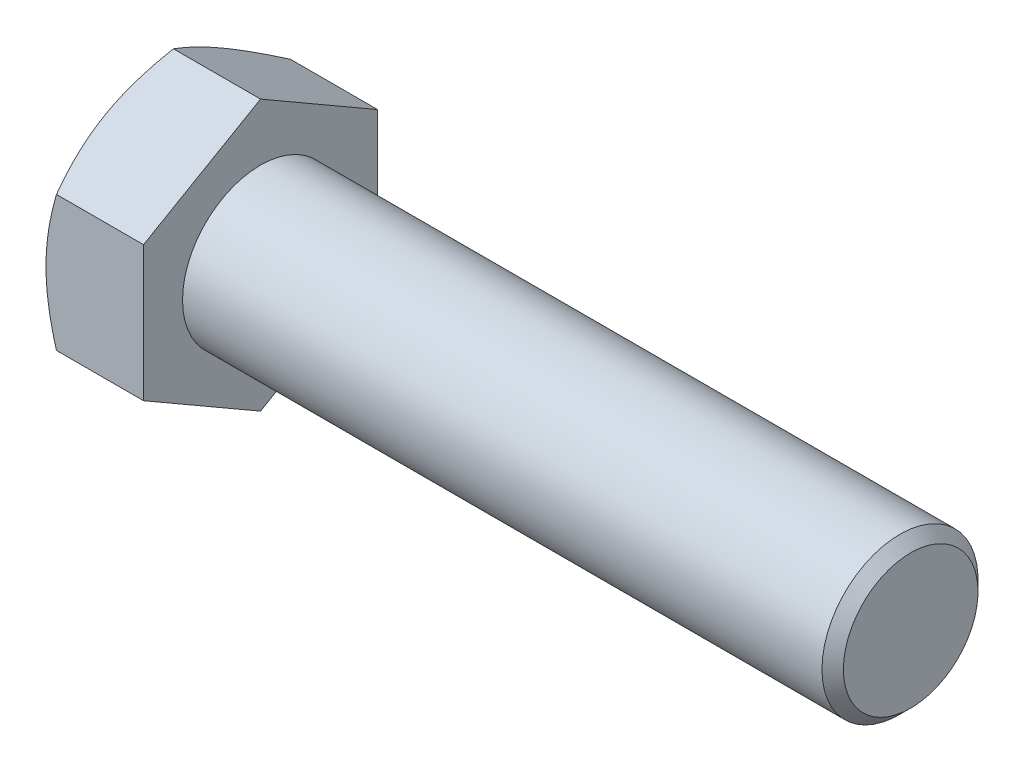
from build123d import *

# Parameters (mm, degrees)
BASEHEAD_DEPTH = 15


with BuildPart() as part:
    # Sketch1 → BaseHead (new body)
    with BuildSketch(Plane(origin=(0, 0, 0), x_dir=(0, 0, -1), z_dir=(1, 0, 0))):
        Polygon((18, 10.392304845), (18, -10.392304845), (0, -20.784609691), (-18, -10.392304845), (-18, 10.392304845), (0, 20.784609691), align=None)
    extrude(amount=BASEHEAD_DEPTH)

    # BodySke → BaseBody (revolve)
    with BuildSketch(Plane.XY):
        Polygon((0, 0), (115, 0), (115, 10.352), (113.352, 12), (0, 12), align=None)
    revolve(axis=Axis((0, 0, 0), (1, 0, 0)))

    # Sketch3 → HeadChamfer (revolve, cut)
    with BuildSketch(Plane.XY):
        Polygon((0, 18), (4.494446501, 25.784609691), (4.494446501, 30.784609691), (-10, 30.784609691), (-10, 18), align=None)
    revolve(axis=Axis((0, 0, 0), (1, 0, 0)), mode=Mode.SUBTRACT)


solid = part.part
